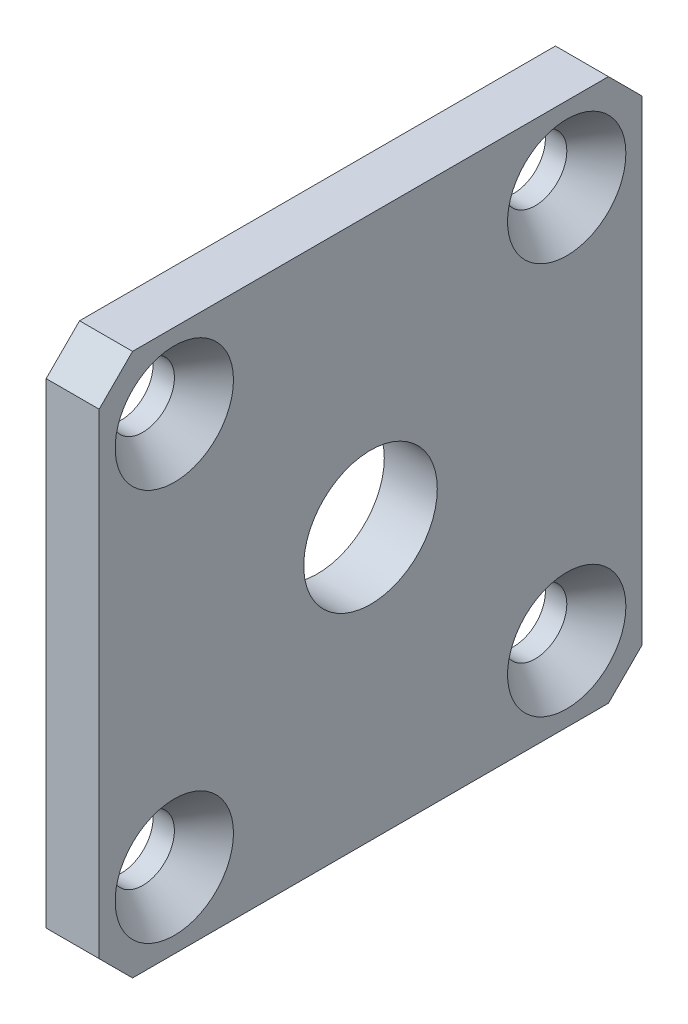
from build123d import *

# Parameters (mm, degrees)
SKETCH1_W                                     = 32.5
SKETCH1_H                                     = 32.5
SKETCH1_R                                     = 4
BOSS_EXTRUDE1_DEPTH                           = 3.175
CHAMFER1_SIZE                                 = 2
CSK_FOR_6_FLAT_HEAD_MACHINE_SCREW1_AT_2_COUNT = 2
CSK_FOR_6_FLAT_HEAD_MACHINE_SCREW1_AT_2_PITCH = 23.5
CSK_FOR_6_FLAT_HEAD_MACHINE_SCREW1_AT_3_COUNT = 2
CSK_FOR_6_FLAT_HEAD_MACHINE_SCREW1_AT_3_PITCH = 33.234018716
CSK_FOR_6_FLAT_HEAD_MACHINE_SCREW1_AT_4_COUNT = 2
CSK_FOR_6_FLAT_HEAD_MACHINE_SCREW1_AT_4_PITCH = 23.5


with BuildPart() as part:
    # Sketch1 → Boss-Extrude1 (new body)
    with BuildSketch(Plane(origin=(0, 0, 0), x_dir=(0, 0, -1), z_dir=(1, 0, 0))):
        Rectangle(SKETCH1_W, SKETCH1_H)
        Circle(SKETCH1_R, mode=Mode.SUBTRACT)
    extrude(amount=BOSS_EXTRUDE1_DEPTH)

    # Chamfer1
    chamfer1_edges = [part.edges().sort_by_distance(p)[0] for p in [
        (1.5875, -16.25, -16.25),
        (1.5875, -16.25, 16.25),
        (1.5875, 16.25, -16.25),
        (1.5875, 16.25, 16.25),
    ]]
    chamfer(chamfer1_edges, length=CHAMFER1_SIZE)

    # Sketch3 → CSK for _6 Flat Head Machine Screw1 (revolve, cut)
    with BuildSketch(Plane(origin=(3.175, 11.75, 11.75), x_dir=(0, 0, -1), z_dir=(0, 1, 0))):
        Polygon((0, 0), (0, 3.175), (1.89865, 3.175), (1.89865, 1.891953401), (3.5433, 0), align=None)
    csk_for_6_flat_head_machine_screw1 = revolve(axis=Axis((9.525, 11.75, 11.75), (-1, 0, 0)), mode=Mode.SUBTRACT)

    # CSK for _6 Flat Head Machine Screw1 at 2: CSK for _6 Flat Head Machine Screw1 ×2
    with Locations(*[(0, 0, -i * CSK_FOR_6_FLAT_HEAD_MACHINE_SCREW1_AT_2_PITCH) for i in range(1, CSK_FOR_6_FLAT_HEAD_MACHINE_SCREW1_AT_2_COUNT)]):
        add(csk_for_6_flat_head_machine_screw1, mode=Mode.SUBTRACT)

    # CSK for _6 Flat Head Machine Screw1 at 3: CSK for _6 Flat Head Machine Screw1 ×2
    with Locations(*[Vector(0, -0.7071067811865476, -0.7071067811865476) * (i * CSK_FOR_6_FLAT_HEAD_MACHINE_SCREW1_AT_3_PITCH) for i in range(1, CSK_FOR_6_FLAT_HEAD_MACHINE_SCREW1_AT_3_COUNT)]):
        add(csk_for_6_flat_head_machine_screw1, mode=Mode.SUBTRACT)

    # CSK for _6 Flat Head Machine Screw1 at 4: CSK for _6 Flat Head Machine Screw1 ×2
    with Locations(*[(0, -i * CSK_FOR_6_FLAT_HEAD_MACHINE_SCREW1_AT_4_PITCH, 0) for i in range(1, CSK_FOR_6_FLAT_HEAD_MACHINE_SCREW1_AT_4_COUNT)]):
        add(csk_for_6_flat_head_machine_screw1, mode=Mode.SUBTRACT)


solid = part.part
